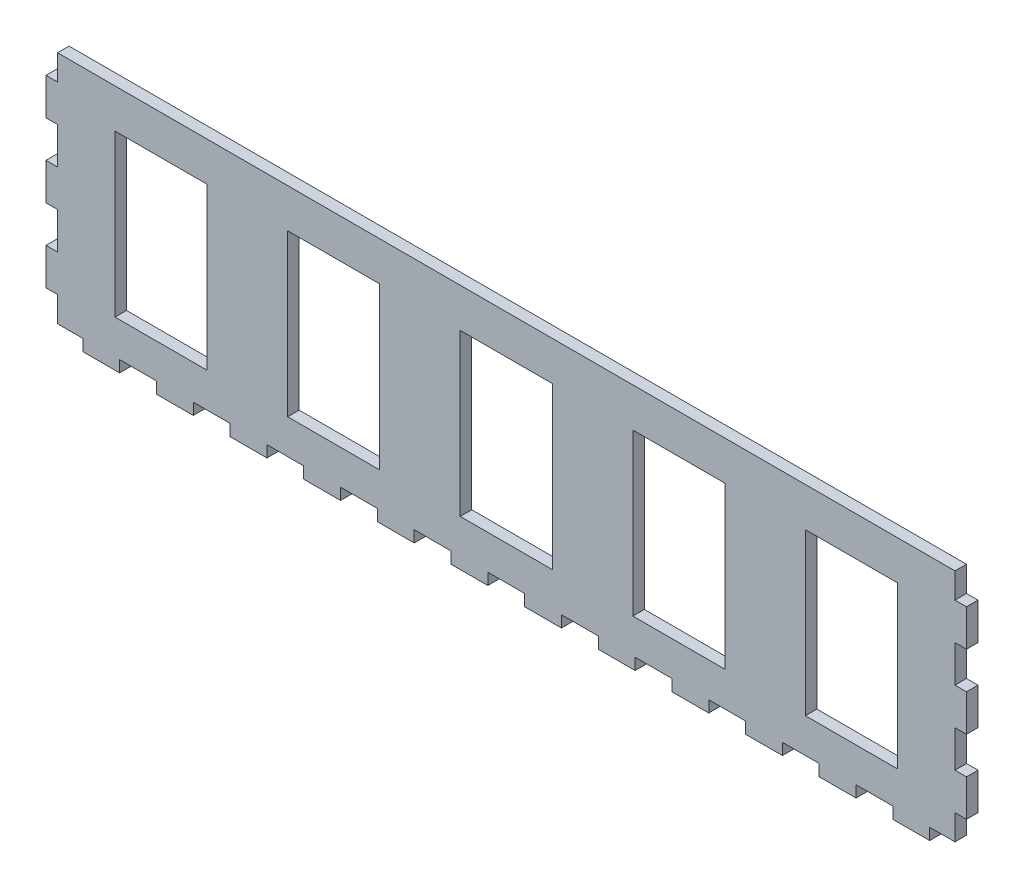
from build123d import *

# Parameters (mm, degrees)
ESQUISSE1_W                = 400
ESQUISSE1_H                = 107
BOSS_EXTRU_1_DEPTH         = 5
ESQUISSE2_W                = 5
ESQUISSE2_H                = 16
ENL_V_MAT_EXTRU_1_DEPTH    = 5
R_P_TITION_LIN_AIRE1_COUNT = 4
R_P_TITION_LIN_AIRE1_PITCH = 32
SYM_TRIE1_COPY_1_SKETCH_W  = 5
SYM_TRIE1_COPY_1_SKETCH_H  = 16
SYM_TRIE1_COPY_1_DEPTH     = 5
SYM_TRIE1_COPY_2_SKETCH_W  = 5
SYM_TRIE1_COPY_2_SKETCH_H  = 16
SYM_TRIE1_COPY_2_DEPTH     = 5
SYM_TRIE1_COPY_3_SKETCH_W  = 5
SYM_TRIE1_COPY_3_SKETCH_H  = 16
SYM_TRIE1_COPY_3_DEPTH     = 5
ESQUISSE3_W                = 16
ESQUISSE3_H                = 5
ENL_V_MAT_EXTRU_2_DEPTH    = 5
R_P_TITION_LIN_AIRE2_COUNT = 13
R_P_TITION_LIN_AIRE2_PITCH = 32
ESQUISSE4_W                = 40
ESQUISSE4_H                = 70
ENL_V_MAT_EXTRU_3_DEPTH    = 10
R_P_TITION_LIN_AIRE3_COUNT = 5
R_P_TITION_LIN_AIRE3_PITCH = 75


with BuildPart() as part:
    # Esquisse1 → Boss.-Extru.1 (new body)
    with BuildSketch(Plane.XY):
        with Locations((200, -53.5)):
            Rectangle(ESQUISSE1_W, ESQUISSE1_H)
    extrude(amount=BOSS_EXTRU_1_DEPTH)

    # Esquisse2 → Enlèv. mat.-Extru.1 (cut)
    with BuildSketch(Plane.XY.offset(5)):
        with Locations((2.5, -99)):
            Rectangle(ESQUISSE2_W, ESQUISSE2_H)
    enl_v_mat_extru_1 = extrude(amount=-ENL_V_MAT_EXTRU_1_DEPTH, mode=Mode.SUBTRACT)

    # Répétition linéaire1: Enlèv. mat.-Extru.1 ×4
    with Locations(*[(0, i * R_P_TITION_LIN_AIRE1_PITCH, 0) for i in range(1, R_P_TITION_LIN_AIRE1_COUNT)]):
        add(enl_v_mat_extru_1, mode=Mode.SUBTRACT)

    # Symétrie1: Enlèv. mat.-Extru.1 across plane
    add(enl_v_mat_extru_1.mirror(Plane.ZY.offset(-200)), mode=Mode.SUBTRACT)

    # Symétrie1 copy 1 sketch → Symétrie1 copy 1 (cut)
    with BuildSketch(Plane(origin=(400, 32, 5), x_dir=(-1, 0, 0), z_dir=(0, 0, 1))):
        with Locations((2.5, 99)):
            Rectangle(SYM_TRIE1_COPY_1_SKETCH_W, SYM_TRIE1_COPY_1_SKETCH_H)
    extrude(amount=-SYM_TRIE1_COPY_1_DEPTH, mode=Mode.SUBTRACT)

    # Symétrie1 copy 2 sketch → Symétrie1 copy 2 (cut)
    with BuildSketch(Plane(origin=(400, 64, 5), x_dir=(-1, 0, 0), z_dir=(0, 0, 1))):
        with Locations((2.5, 99)):
            Rectangle(SYM_TRIE1_COPY_2_SKETCH_W, SYM_TRIE1_COPY_2_SKETCH_H)
    extrude(amount=-SYM_TRIE1_COPY_2_DEPTH, mode=Mode.SUBTRACT)

    # Symétrie1 copy 3 sketch → Symétrie1 copy 3 (cut)
    with BuildSketch(Plane(origin=(400, 96, 5), x_dir=(-1, 0, 0), z_dir=(0, 0, 1))):
        with Locations((2.5, 99)):
            Rectangle(SYM_TRIE1_COPY_3_SKETCH_W, SYM_TRIE1_COPY_3_SKETCH_H)
    extrude(amount=-SYM_TRIE1_COPY_3_DEPTH, mode=Mode.SUBTRACT)

    # Esquisse3 → Enlèv. mat.-Extru.2 (cut)
    with BuildSketch(Plane.XY.offset(5)):
        with Locations((8, -104.5)):
            Rectangle(ESQUISSE3_W, ESQUISSE3_H)
    enl_v_mat_extru_2 = extrude(amount=-ENL_V_MAT_EXTRU_2_DEPTH, mode=Mode.SUBTRACT)

    # Répétition linéaire2: Enlèv. mat.-Extru.2 ×13
    with Locations(*[(i * R_P_TITION_LIN_AIRE2_PITCH, 0, 0) for i in range(1, R_P_TITION_LIN_AIRE2_COUNT)]):
        add(enl_v_mat_extru_2, mode=Mode.SUBTRACT)

    # Esquisse4 → Enlèv. mat.-Extru.3 (cut)
    with BuildSketch(Plane.XY.offset(5)):
        with Locations((50, -52)):
            Rectangle(ESQUISSE4_W, ESQUISSE4_H)
    enl_v_mat_extru_3 = extrude(amount=-ENL_V_MAT_EXTRU_3_DEPTH, mode=Mode.SUBTRACT)

    # Répétition linéaire3: Enlèv. mat.-Extru.3 ×5
    with Locations(*[(i * R_P_TITION_LIN_AIRE3_PITCH, 0, 0) for i in range(1, R_P_TITION_LIN_AIRE3_COUNT)]):
        add(enl_v_mat_extru_3, mode=Mode.SUBTRACT)


solid = part.part
